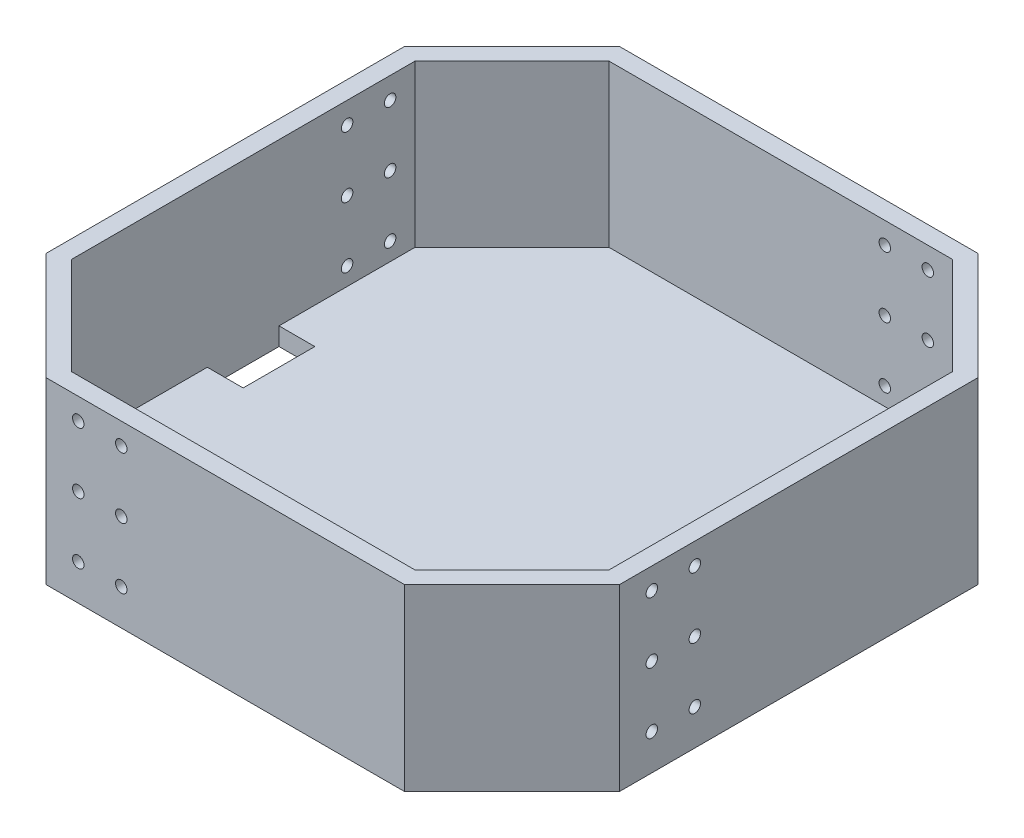
from build123d import *

# Parameters (mm, degrees)
BOSS_EXTRUDE1_DEPTH = 50
SHELL1_T            = -5
SKETCH5_W           = 10
SKETCH5_H           = 20
CUT_EXTRUDE1_DEPTH  = 5
SKETCH6_R           = 1.6
CUT_EXTRUDE2_DEPTH  = 5
CIRPATTERN1_COUNT   = 4


with BuildPart() as part:
    # Sketch1 → Boss-Extrude1 (new body)
    with BuildSketch(Plane(origin=(0, 0, 0), x_dir=(1, 0, 0), z_dir=(0, 1, 0))):
        Polygon((-50, 80), (-80, 50), (-80, -50), (-50, -80), (50, -80), (80, -50), (80, 50), (50, 80), align=None)
    extrude(amount=BOSS_EXTRUDE1_DEPTH)

    # Shell1
    shell1_openings = [part.faces().sort_by_distance(p)[0] for p in [
        (0, 50, 0),
    ]]
    offset(amount=SHELL1_T, openings=shell1_openings, kind=Kind.INTERSECTION)

    # Sketch5 → Cut-Extrude1 (cut)
    with BuildSketch(Plane(origin=(0, 5, 0), x_dir=(1, 0, 0), z_dir=(0, 1, 0))):
        with Locations((-70, 0)):
            Rectangle(SKETCH5_W, SKETCH5_H)
    extrude(amount=-CUT_EXTRUDE1_DEPTH, mode=Mode.SUBTRACT)

    # Sketch6 → Cut-Extrude2 (cut)
    with BuildSketch(Plane.XY.offset(80)):
        with Locations((-29, 10)):
            Circle(SKETCH6_R)
        with Locations((-41, 10)):
            Circle(SKETCH6_R)
        with Locations((-29, 27)):
            Circle(SKETCH6_R)
        with Locations((-41, 27)):
            Circle(SKETCH6_R)
        with Locations((-29, 44)):
            Circle(SKETCH6_R)
        with Locations((-41, 44)):
            Circle(SKETCH6_R)
    cut_extrude2 = extrude(amount=-CUT_EXTRUDE2_DEPTH, mode=Mode.SUBTRACT)

    # CirPattern1: Cut-Extrude2 ×4 about axis
    cirpattern1_axis = Axis((0, 52.5, 0), (0, -1, 0))
    for i in range(1, CIRPATTERN1_COUNT):
        add(cut_extrude2.rotate(cirpattern1_axis, i * 360 / CIRPATTERN1_COUNT), mode=Mode.SUBTRACT)


solid = part.part
